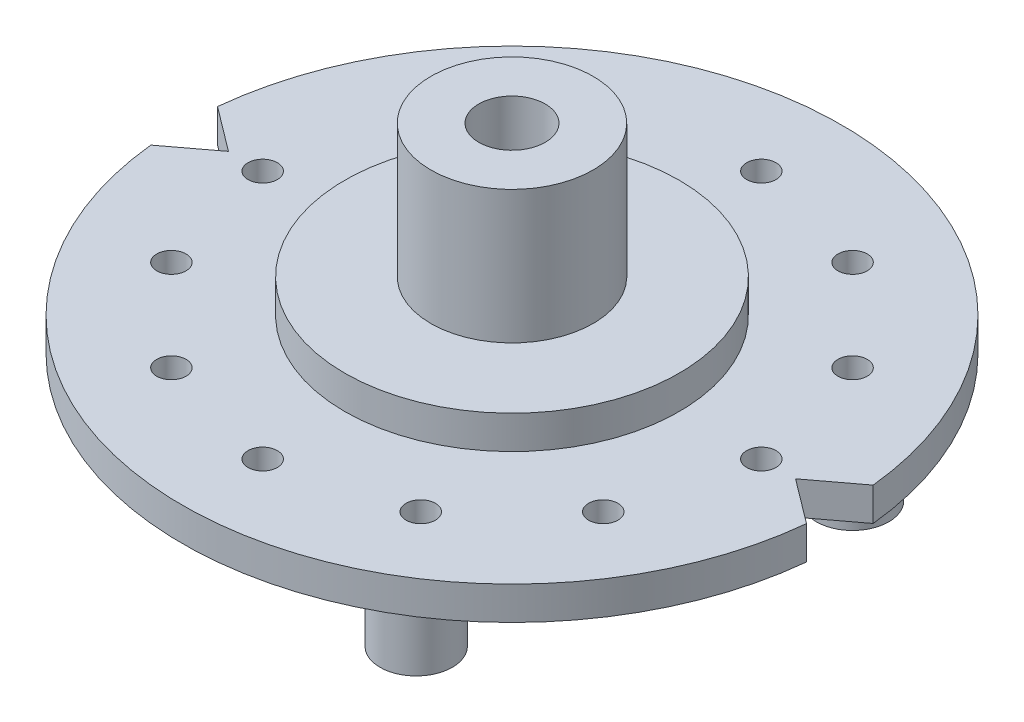
from build123d import *

# Parameters (mm, degrees)
CROQUIS1_R              = 1.905
CROQUIS1_R_2            = 21.717
SALIENTE_EXTRUIR1_DEPTH = 4.318
CROQUIS1_3_R            = 21.717
CROQUIS1_3_R_2          = 10.541
SALIENTE_EXTRUIR2_DEPTH = 8.636
CROQUIS1_4_R            = 10.541
SALIENTE_EXTRUIR3_DEPTH = 25.908
TALADRO1_D              = 8.636
TALADRO1_DEPTH          = 21.59
CROQUIS5_R              = 4.699
SALIENTE_EXTRUIR4_DEPTH = 10.668
MATRIZC1_COUNT          = 4


with BuildPart() as part:
    # Croquis1 → Saliente-Extruir1 (new body)
    with BuildSketch(Plane(origin=(0, 0, 0), x_dir=(1, 0, 0), z_dir=(0, 1, 0))):
        with BuildLine():
            Line((-36.83, 0), (-42.579167494, -4.33230845))
            ThreePointArc((-42.579167494, -4.33230845), (0, -42.799), (42.579167494, -4.33230845))
            Line((42.579167494, -4.33230845), (36.83, 0))
            Line((36.83, 0), (42.579167494, 4.33230845))
            ThreePointArc((42.579167494, 4.33230845), (0, 42.799), (-42.579167494, 4.33230845))
            Line((-42.579167494, 4.33230845), (-36.83, 0))
        make_face()
        with Locations((32.385, 0)):
            Circle(CROQUIS1_R, mode=Mode.SUBTRACT)
        with Locations((28.046232702, 16.1925)):
            Circle(CROQUIS1_R, mode=Mode.SUBTRACT)
        with Locations((16.1925, 28.046232702)):
            Circle(CROQUIS1_R, mode=Mode.SUBTRACT)
        with Locations((0, 32.385)):
            Circle(CROQUIS1_R, mode=Mode.SUBTRACT)
        with Locations((-16.1925, 28.046232702)):
            Circle(CROQUIS1_R, mode=Mode.SUBTRACT)
        with Locations((-28.046232702, 16.1925)):
            Circle(CROQUIS1_R, mode=Mode.SUBTRACT)
        with Locations((-32.385, 0)):
            Circle(CROQUIS1_R, mode=Mode.SUBTRACT)
        with Locations((-28.046232702, -16.1925)):
            Circle(CROQUIS1_R, mode=Mode.SUBTRACT)
        with Locations((-16.1925, -28.046232702)):
            Circle(CROQUIS1_R, mode=Mode.SUBTRACT)
        with Locations((0, -32.385)):
            Circle(CROQUIS1_R, mode=Mode.SUBTRACT)
        with Locations((16.1925, -28.046232702)):
            Circle(CROQUIS1_R, mode=Mode.SUBTRACT)
        with Locations((28.046232702, -16.1925)):
            Circle(CROQUIS1_R, mode=Mode.SUBTRACT)
        Circle(CROQUIS1_R_2, mode=Mode.SUBTRACT)
    extrude(amount=SALIENTE_EXTRUIR1_DEPTH)

    # Croquis1_3 → Saliente-Extruir2 (add)
    with BuildSketch(Plane(origin=(0, 0, 0), x_dir=(1, 0, 0), z_dir=(0, 1, 0))):
        Circle(CROQUIS1_3_R)
        Circle(CROQUIS1_3_R_2, mode=Mode.SUBTRACT)
    extrude(amount=SALIENTE_EXTRUIR2_DEPTH)

    # Croquis1_4 → Saliente-Extruir3 (add)
    with BuildSketch(Plane(origin=(0, 0, 0), x_dir=(1, 0, 0), z_dir=(0, 1, 0))):
        Circle(CROQUIS1_4_R)
    extrude(amount=SALIENTE_EXTRUIR3_DEPTH)

    # Taladro1
    with Locations(Plane(origin=(0, 25.908, 0), x_dir=(1, 0, 0), z_dir=(0, 1, 0))):
        with Locations((0, 0)):
            Hole(TALADRO1_D / 2, depth=TALADRO1_DEPTH)

    # Croquis5 → Saliente-Extruir4 (add)
    with BuildSketch(Plane.XZ):
        with Locations((28.046232702, -16.1925)):
            Circle(CROQUIS5_R)
    saliente_extruir4 = extrude(amount=SALIENTE_EXTRUIR4_DEPTH)

    # MatrizC1: Saliente-Extruir4 ×4 about axis
    matrizc1_axis = Axis((-0.295191575, 0, 0.170428935), (0, 1, 0))
    for i in range(1, MATRIZC1_COUNT):
        add(saliente_extruir4.rotate(matrizc1_axis, i * 360 / MATRIZC1_COUNT))


solid = part.part
